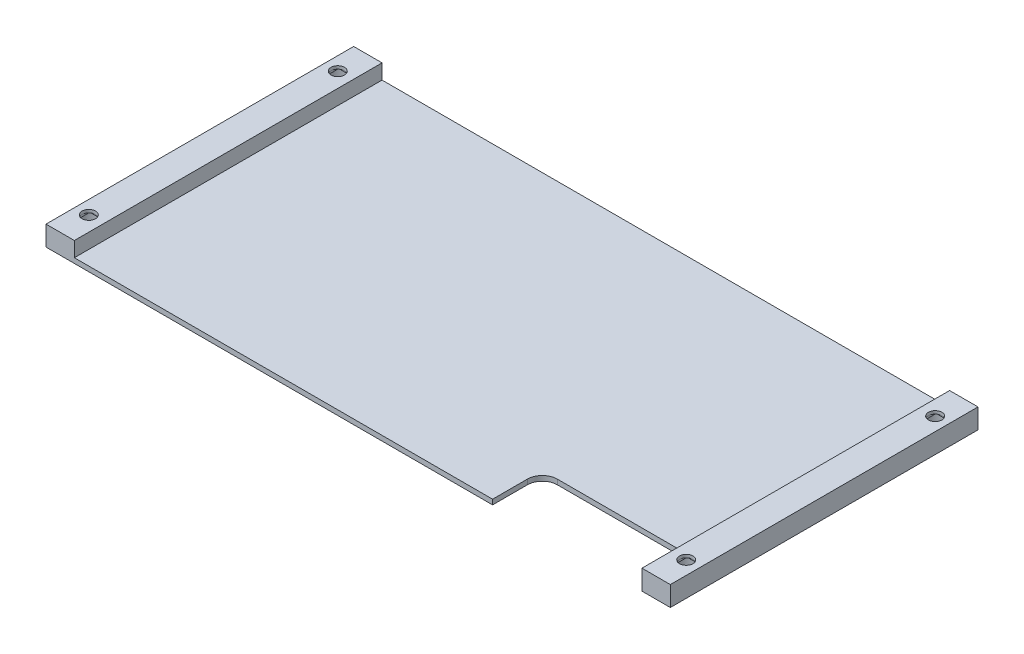
from build123d import *

# Parameters (mm, degrees)
SKETCH1_W           = 126
SKETCH1_H           = 61.8
BOSS_EXTRUDE1_DEPTH = 1
SKETCH2_W           = 6
SKETCH2_H           = 61.8
BOSS_EXTRUDE2_DEPTH = 3
SKETCH3_R           = 1.35
CUT_EXTRUDE1_DEPTH  = 5
SKETCH4_R           = 2.5
CUT_EXTRUDE2_DEPTH  = 3
SKETCH5_W           = 30
SKETCH5_H           = 10
CUT_EXTRUDE3_DEPTH  = 5
FILLET1_R           = 3
CUT_EXTRUDE4_DEPTH  = 0.2
SKETCH7_W           = 2.7
SKETCH7_H           = 2.7
CUT_EXTRUDE5_DEPTH  = 0.2
SKETCH8_W           = 0.3
SKETCH8_H           = 61.8
CUT_EXTRUDE6_DEPTH  = 5


with BuildPart() as part:
    # Sketch1 → Boss-Extrude1 (new body)
    with BuildSketch(Plane(origin=(0, 0, 0), x_dir=(1, 0, 0), z_dir=(0, 1, 0))):
        Rectangle(SKETCH1_W, SKETCH1_H)
    extrude(amount=BOSS_EXTRUDE1_DEPTH)

    # Sketch2 → Boss-Extrude2 (add)
    with BuildSketch(Plane(origin=(0, 1, 0), x_dir=(1, 0, 0), z_dir=(0, 1, 0))):
        with Locations((-60, 0)):
            Rectangle(SKETCH2_W, SKETCH2_H)
        with Locations((60, 0)):
            Rectangle(SKETCH2_W, SKETCH2_H)
    extrude(amount=BOSS_EXTRUDE2_DEPTH)

    # Sketch3 → Cut-Extrude1 (cut, through all)
    with BuildSketch(Plane(origin=(0, 4, 0), x_dir=(1, 0, 0), z_dir=(0, 1, 0))):
        with Locations((-60, 25)):
            Circle(SKETCH3_R)
        with Locations((-60, -25)):
            Circle(SKETCH3_R)
        with Locations((60, -25)):
            Circle(SKETCH3_R)
        with Locations((60, 25)):
            Circle(SKETCH3_R)
    extrude(amount=-CUT_EXTRUDE1_DEPTH, mode=Mode.SUBTRACT)

    # Sketch4 → Cut-Extrude2 (cut)
    with BuildSketch(Plane.XZ):
        with Locations((60, -25)):
            Circle(SKETCH4_R)
        with Locations((60, 25)):
            Circle(SKETCH4_R)
        with Locations((-60, 25)):
            Circle(SKETCH4_R)
        with Locations((-60, -25)):
            Circle(SKETCH4_R)
    extrude(amount=-CUT_EXTRUDE2_DEPTH, mode=Mode.SUBTRACT)

    # Sketch5 → Cut-Extrude3 (cut, through all)
    with BuildSketch(Plane.XZ):
        with Locations((42, 25.9)):
            Rectangle(SKETCH5_W, SKETCH5_H)
    extrude(amount=-CUT_EXTRUDE3_DEPTH, mode=Mode.SUBTRACT)

    # Fillet1
    fillet1_edges = [part.edges().sort_by_distance(p)[0] for p in [
        (27, 0.5, 20.9),
        (57, 0.5, 20.9),
    ]]
    fillet(fillet1_edges, radius=FILLET1_R)

    # Sketch6 → Cut-Extrude4 (cut)
    with BuildSketch(Plane.XZ.offset(-3)):
        with BuildLine():
            Line((-61.35, 22.895837459), (-61.35, 27.104162541))
            ThreePointArc((-61.35, 27.104162541), (-60, 27.5), (-58.65, 27.104162541))
            Line((-58.65, 27.104162541), (-58.65, 22.895837459))
            ThreePointArc((-58.65, 22.895837459), (-60, 22.5), (-61.35, 22.895837459))
        make_face()
        with BuildLine():
            Line((-61.35, -27.104162541), (-61.35, -22.895837459))
            ThreePointArc((-61.35, -22.895837459), (-60, -22.5), (-58.65, -22.895837459))
            Line((-58.65, -22.895837459), (-58.65, -27.104162541))
            ThreePointArc((-58.65, -27.104162541), (-60, -27.5), (-61.35, -27.104162541))
        make_face()
    cut_extrude4 = extrude(amount=-CUT_EXTRUDE4_DEPTH, mode=Mode.SUBTRACT)

    # Sketch7 → Cut-Extrude5 (cut)
    with BuildSketch(Plane.XZ.offset(-3.2)):
        with Locations((-60, -25)):
            Rectangle(SKETCH7_W, SKETCH7_H)
        with Locations((-60, 25)):
            Rectangle(SKETCH7_W, SKETCH7_H)
    cut_extrude5 = extrude(amount=-CUT_EXTRUDE5_DEPTH, mode=Mode.SUBTRACT)

    # Mirror1: Cut-Extrude4, Cut-Extrude5 across plane
    add(cut_extrude4.mirror(Plane(origin=(0, 0, 0), x_dir=(0, 0, 1), z_dir=(1, 0, 0))), mode=Mode.SUBTRACT)
    add(cut_extrude5.mirror(Plane(origin=(0, 0, 0), x_dir=(0, 0, 1), z_dir=(1, 0, 0))), mode=Mode.SUBTRACT)

    # Sketch8 → Cut-Extrude6 (cut, through all)
    with BuildSketch(Plane(origin=(0, 4, 0), x_dir=(1, 0, 0), z_dir=(0, 1, 0))):
        with Locations((-62.85, 0)):
            Rectangle(SKETCH8_W, SKETCH8_H)
        with Locations((62.85, 0)):
            Rectangle(SKETCH8_W, SKETCH8_H)
    extrude(amount=-CUT_EXTRUDE6_DEPTH, mode=Mode.SUBTRACT)


solid = part.part
